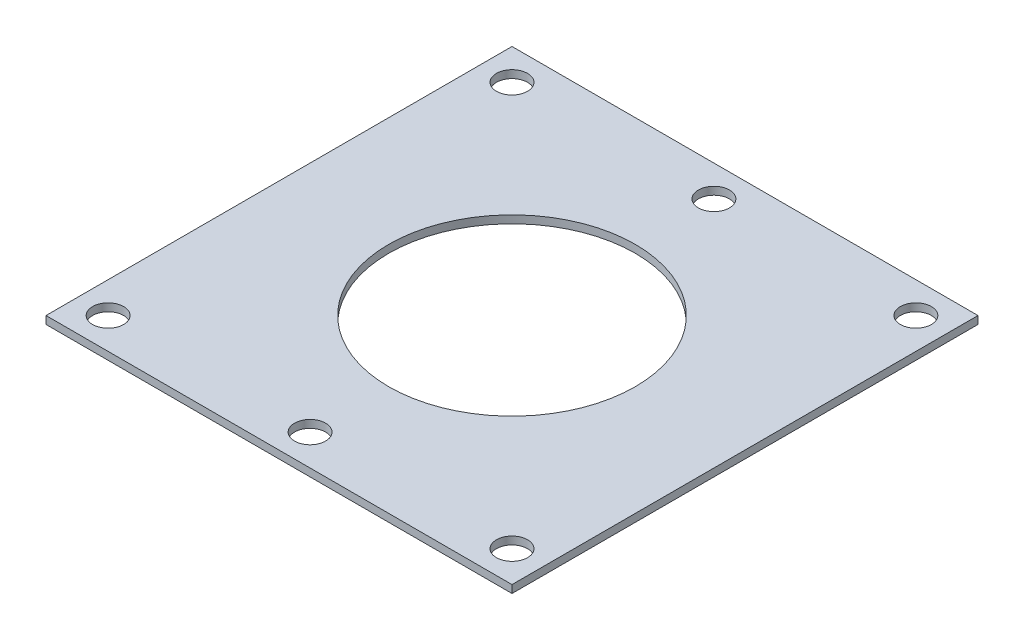
from build123d import *

# Parameters (mm, degrees)
SKETCH1_W           = 60
SKETCH1_H           = 60
BOSS_EXTRUDE1_DEPTH = 1
SKETCH2_R           = 2
CUT_EXTRUDE1_DEPTH  = 2
SKETCH4_R           = 15.875
CUT_EXTRUDE3_DEPTH  = 10


with BuildPart() as part:
    # Sketch1 → Boss-Extrude1 (new body)
    with BuildSketch(Plane(origin=(0, 0, 0), x_dir=(1, 0, 0), z_dir=(0, 1, 0))):
        Rectangle(SKETCH1_W, SKETCH1_H)
    extrude(amount=BOSS_EXTRUDE1_DEPTH)

    # Sketch2 → Cut-Extrude1 (cut, through all)
    with BuildSketch(Plane(origin=(0, 1, 0), x_dir=(1, 0, 0), z_dir=(0, 1, 0))):
        with Locations((-26, 26)):
            Circle(SKETCH2_R)
        with Locations((0, 26)):
            Circle(SKETCH2_R)
        with Locations((26, 26)):
            Circle(SKETCH2_R)
        with Locations((26, -26)):
            Circle(SKETCH2_R)
        with Locations((0, -26)):
            Circle(SKETCH2_R)
        with Locations((-26, -26)):
            Circle(SKETCH2_R)
    extrude(amount=-CUT_EXTRUDE1_DEPTH, mode=Mode.SUBTRACT)

    # Sketch4 → Cut-Extrude3 (cut)
    with BuildSketch(Plane(origin=(0, 1, 0), x_dir=(1, 0, 0), z_dir=(0, 1, 0))):
        Circle(SKETCH4_R)
    extrude(amount=-CUT_EXTRUDE3_DEPTH, mode=Mode.SUBTRACT)


solid = part.part
